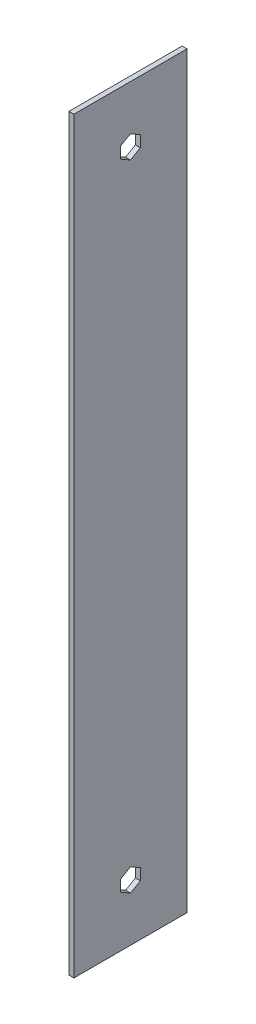
from build123d import *

# Parameters (mm, degrees)
SKETCH1_W           = 73.025
SKETCH1_H           = 482.6
BOSS_EXTRUDE1_DEPTH = 1.5875


with BuildPart() as part:
    # Sketch1 → Boss-Extrude1 (new body, symmetric)
    with BuildSketch(Plane(origin=(0, 0, 0), x_dir=(0, 0, -1), z_dir=(1, 0, 0))):
        with Locations((0, 204.7875)):
            Rectangle(SKETCH1_W, SKETCH1_H)
        Polygon((0, 7.332348419), (-6.35, 3.666174209), (-6.35, -3.666174209), (0, -7.332348419), (6.35, -3.666174209), (6.35, 3.666174209), align=None, mode=Mode.SUBTRACT)
        Polygon((0, 402.242651581), (6.35, 405.908825791), (6.35, 413.241174209), (0, 416.907348419), (-6.35, 413.241174209), (-6.35, 405.908825791), align=None, mode=Mode.SUBTRACT)
    extrude(amount=BOSS_EXTRUDE1_DEPTH, both=True)


solid = part.part
